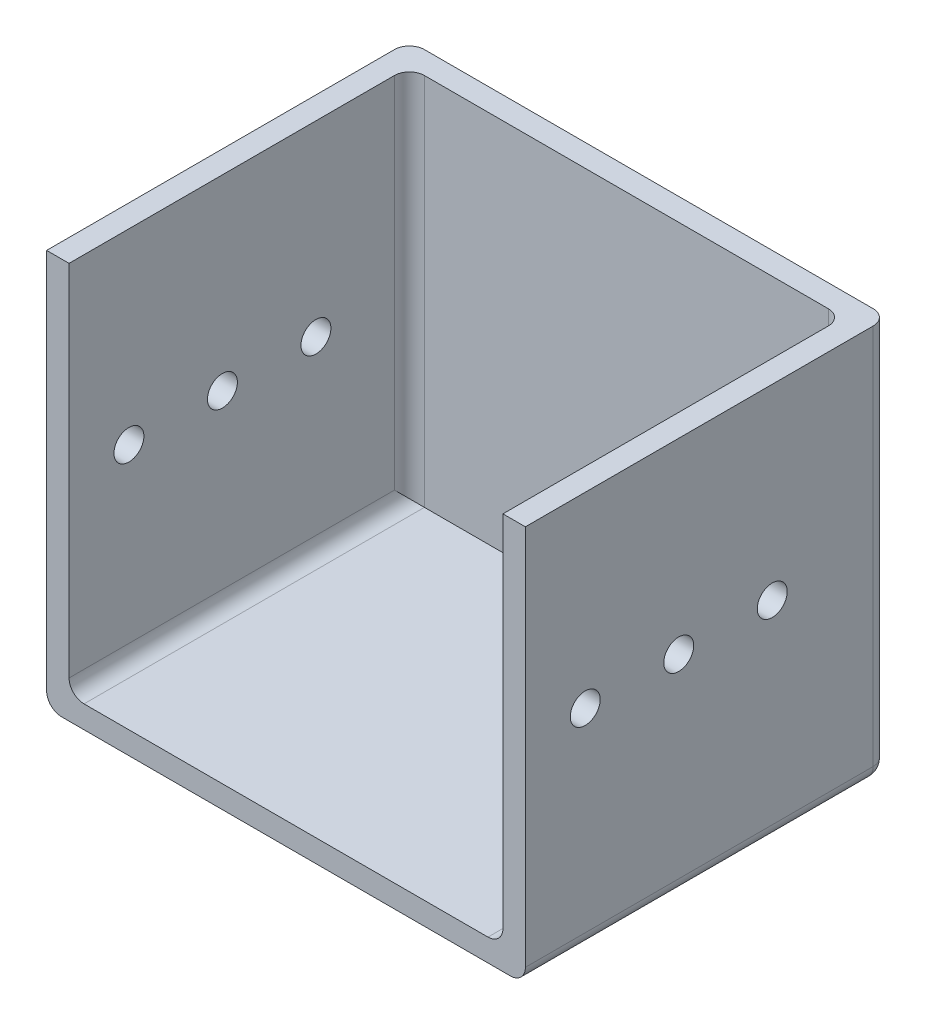
from build123d import *

# Parameters (mm, degrees)
SKETCH_1_W          = 64
SKETCH_1_H          = 48.5
EXTRUDE_1_DEPTH     = 3
EXTRUDE_2_DEPTH     = 50
FILLET_2_R          = 2
SKETCH_3_R          = 2
CUT_EXTRUDE_1_DEPTH = 65
FILLET_3_R          = 2


with BuildPart() as part:
    # Эскиз1 → Бобышка-Вытянуть1 (new body)
    with BuildSketch(Plane(origin=(0, 0, 0), x_dir=(1, 0, 0), z_dir=(0, 1, 0))):
        Rectangle(SKETCH_1_W, SKETCH_1_H)
    extrude(amount=EXTRUDE_1_DEPTH)

    # Эскиз2 → Бобышка-Вытянуть2 (add)
    with BuildSketch(Plane(origin=(0, 3, 0), x_dir=(1, 0, 0), z_dir=(0, 1, 0))):
        Polygon((-32, -24.25), (-32, 24.25), (32, 24.25), (32, -24.25), (29, -24.25), (29, 21.25), (-29, 21.25), (-29, -24.25), align=None)
    extrude(amount=EXTRUDE_2_DEPTH)

    # Скругление2
    fillet_2_edges = [part.edges().sort_by_distance(p)[0] for p in [
        (0, 0, -24.25),
    ]]
    fillet(fillet_2_edges, radius=FILLET_2_R)

    # Эскиз3 → Вырез-Вытянуть1 (cut, through all)
    with BuildSketch(Plane(origin=(32, 0, 0), x_dir=(0, 0, -1), z_dir=(1, 0, 0))):
        with Locations((8.75, 28)):
            Circle(SKETCH_3_R)
        with Locations((-3.75, 28)):
            Circle(SKETCH_3_R)
        with Locations((-16.25, 28)):
            Circle(SKETCH_3_R)
    extrude(amount=-CUT_EXTRUDE_1_DEPTH, mode=Mode.SUBTRACT)

    # Скругление3
    fillet_3_edges = [part.edges().sort_by_distance(p)[0] for p in [
        (-29, 3, 1.5),
        (-29, 28, -21.25),
        (29, 3, 1.5),
        (29, 28, -21.25),
        (-32, 0, 1),
        (-32, 0.585786438, -23.664213562),
        (32, 0.585786438, -23.664213562),
        (32, 0, 1),
        (-32, 27.5, -24.25),
        (32, 27.5, -24.25),
    ]]
    fillet(fillet_3_edges, radius=FILLET_3_R)


solid = part.part
